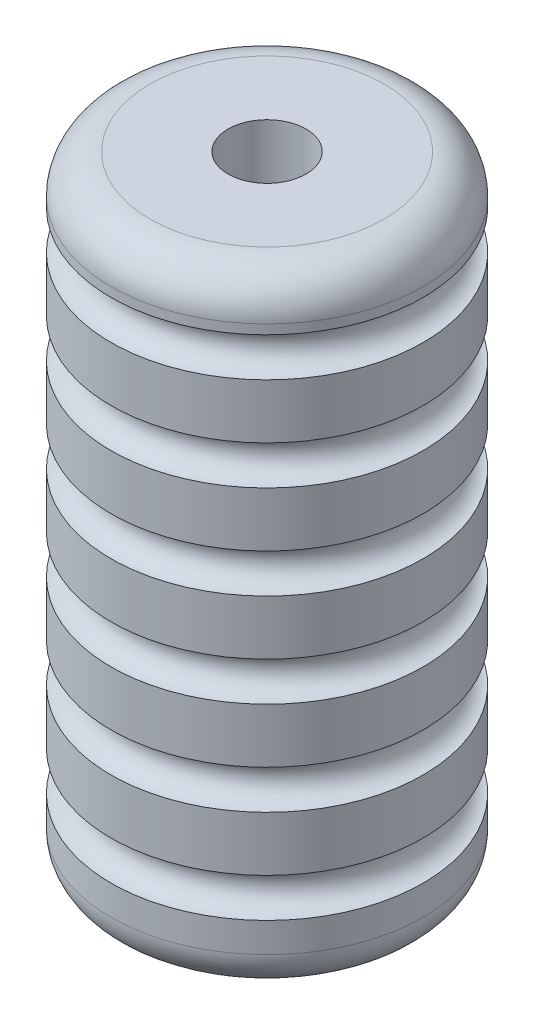
from build123d import *

# Parameters (mm, degrees)
SKETCH3_R          = 6.35
CUT_EXTRUDE1_DEPTH = 102.6


with BuildPart() as part:
    # Sketch2 → Revolve1 (revolve)
    with BuildSketch(Plane(origin=(0, 0, 0), x_dir=(0, 0, -1), z_dir=(1, 0, 0))):
        with BuildLine():
            Line((25.4, 93.722717927), (25.4, 95.25))
            ThreePointArc((25.4, 95.25), (23.540128061, 99.740128061), (19.05, 101.6))
            Line((19.05, 101.6), (0, 101.6))
            Line((0, 101.6), (0, 0))
            Line((0, 0), (19.05, 0))
            ThreePointArc((19.05, 0), (23.540128061, 1.859871939), (25.4, 6.35))
            Line((25.4, 6.35), (25.4, 11.172717927))
            ThreePointArc((25.4, 11.172717927), (22.225, 14.347717927), (25.4, 17.522717927))
            Line((25.4, 17.522717927), (25.4, 26.412717927))
            ThreePointArc((25.4, 26.412717927), (22.225, 29.587717927), (25.4, 32.762717927))
            Line((25.4, 32.762717927), (25.4, 41.652717927))
            ThreePointArc((25.4, 41.652717927), (22.225, 44.827717927), (25.4, 48.002717927))
            Line((25.4, 48.002717927), (25.4, 56.892717927))
            ThreePointArc((25.4, 56.892717927), (22.225, 60.067717927), (25.4, 63.242717927))
            Line((25.4, 63.242717927), (25.4, 72.132717927))
            ThreePointArc((25.4, 72.132717927), (22.225, 75.307717927), (25.4, 78.482717927))
            Line((25.4, 78.482717927), (25.4, 87.372717927))
            ThreePointArc((25.4, 87.372717927), (22.225, 90.547717927), (25.4, 93.722717927))
        make_face()
    revolve(axis=Axis((0, 0, 0), (0, 1, 0)))

    # Sketch3 → Cut-Extrude1 (cut, through all)
    with BuildSketch(Plane(origin=(0, 101.6, 0), x_dir=(1, 0, 0), z_dir=(0, 1, 0))):
        Circle(SKETCH3_R)
    extrude(amount=-CUT_EXTRUDE1_DEPTH, mode=Mode.SUBTRACT)


solid = part.part
